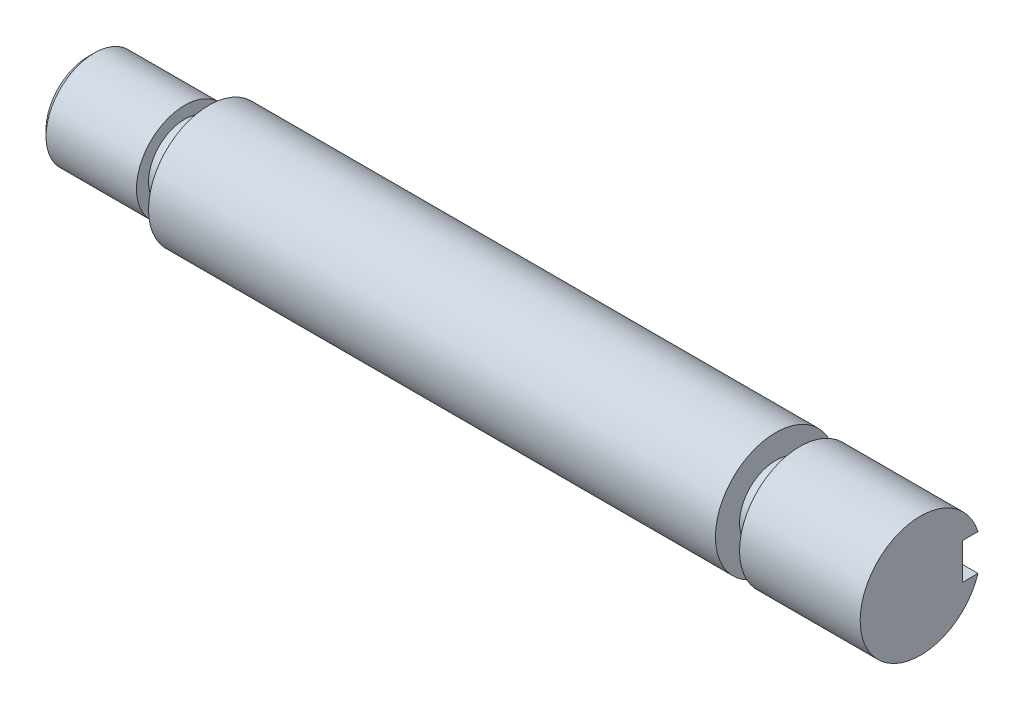
from build123d import *

# Parameters (mm, degrees)
SKETCH1_R           = 5
BOSS_EXTRUDE1_DEPTH = 34.5
CUT_EXTRUDE1_START  = -10
SKETCH2_R           = 5
SKETCH2_R_2         = 3
CUT_EXTRUDE1_DEPTH  = 2
CUT_EXTRUDE4_START  = -3.5
CUT_EXTRUDE4_DEPTH  = 3.2
CHAMFER1_SIZE       = 0.5
SKETCH4_OUTSIDE_W   = 26.086
SKETCH4_OUTSIDE_H   = 26.086
SKETCH4_OUTSIDE_R   = 4
CUT_EXTRUDE5_DEPTH  = 8
CHAMFER2_SIZE       = 0.5
CUT_EXTRUDE6_START  = -8
SKETCH6_OUTSIDE_W   = 26.086
SKETCH6_OUTSIDE_H   = 26.086
SKETCH6_OUTSIDE_R   = 3
CUT_EXTRUDE6_DEPTH  = 2


with BuildPart() as part:
    # Sketch1 → Boss-Extrude1 (new body, symmetric)
    with BuildSketch(Plane(origin=(0, 0, 0), x_dir=(0, 0, -1), z_dir=(1, 0, 0))):
        Circle(SKETCH1_R)
    extrude(amount=BOSS_EXTRUDE1_DEPTH, both=True)

    # Sketch2 → Cut-Extrude1 (cut)
    with BuildSketch(Plane(origin=(34.5, 0, 0), x_dir=(0, 0, -1), z_dir=(1, 0, 0)).offset(CUT_EXTRUDE1_START)):
        Circle(SKETCH2_R)
        Circle(SKETCH2_R_2, mode=Mode.SUBTRACT)
    extrude(amount=-CUT_EXTRUDE1_DEPTH, mode=Mode.SUBTRACT)

    # Sketch3 → Cut-Extrude4 (cut)
    with BuildSketch(Plane.XY.offset(CUT_EXTRUDE4_START)):
        with BuildLine():
            Line((68.42289795, -1.5), (9, -1.5))
            ThreePointArc((9, -1.5), (7.5, 0), (9, 1.5))
            Line((9, 1.5), (68.42289795, 1.5))
            Line((68.42289795, 1.5), (68.42289795, -1.5))
        make_face()
    extrude(amount=-CUT_EXTRUDE4_DEPTH, mode=Mode.SUBTRACT)

    # Chamfer1
    chamfer1_edges = [part.edges().sort_by_distance(p)[0] for p in [
        (-34.5, 0, 5),
    ]]
    chamfer(chamfer1_edges, length=CHAMFER1_SIZE)

    # Sketch4 outside → Cut-Extrude5 (cut)
    with BuildSketch(Plane.ZY.offset(34.5)):
        Rectangle(SKETCH4_OUTSIDE_W, SKETCH4_OUTSIDE_H)
        Circle(SKETCH4_OUTSIDE_R, mode=Mode.SUBTRACT)
    extrude(amount=-CUT_EXTRUDE5_DEPTH, mode=Mode.SUBTRACT)

    # Chamfer2
    chamfer2_edges = [part.edges().sort_by_distance(p)[0] for p in [
        (-34.5, 0, -4),
    ]]
    chamfer(chamfer2_edges, length=CHAMFER2_SIZE)

    # Sketch6 outside → Cut-Extrude6 (cut)
    with BuildSketch(Plane.ZY.offset(34.5).offset(CUT_EXTRUDE6_START)):
        Rectangle(SKETCH6_OUTSIDE_W, SKETCH6_OUTSIDE_H)
        Circle(SKETCH6_OUTSIDE_R, mode=Mode.SUBTRACT)
    extrude(amount=-CUT_EXTRUDE6_DEPTH, mode=Mode.SUBTRACT)


solid = part.part
